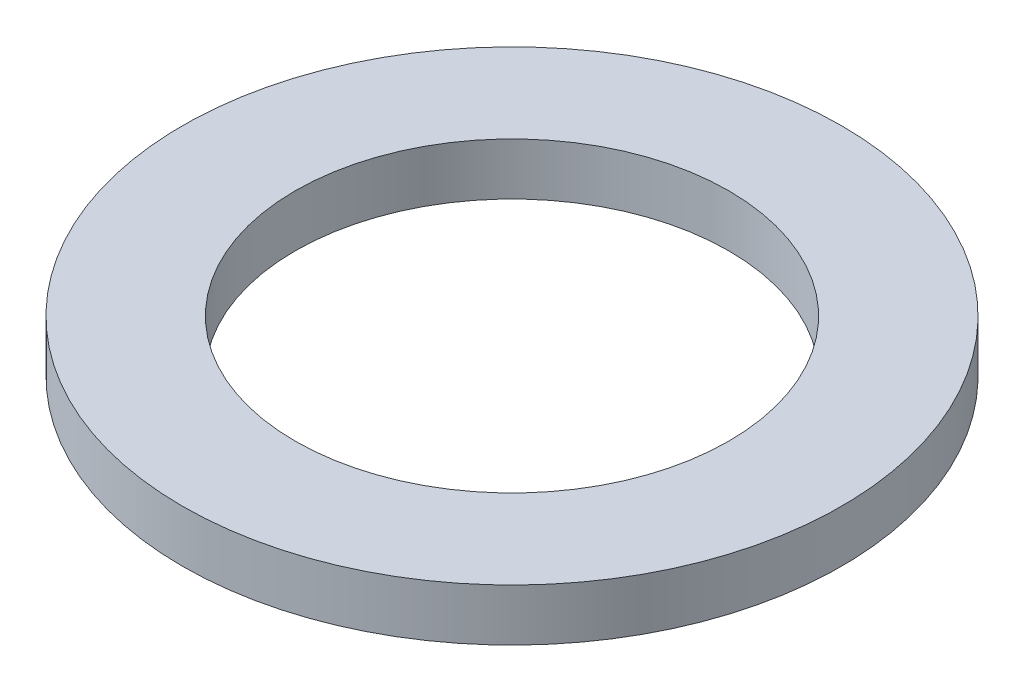
from build123d import *

# Parameters (mm, degrees)
SKETCH1_R           = 19
SKETCH1_R_2         = 12.5
BOSS_EXTRUDE1_DEPTH = 3


with BuildPart() as part:
    # Sketch1 → Boss-Extrude1 (new body)
    with BuildSketch(Plane(origin=(0, 0, 0), x_dir=(1, 0, 0), z_dir=(0, 1, 0))):
        Circle(SKETCH1_R)
        Circle(SKETCH1_R_2, mode=Mode.SUBTRACT)
    extrude(amount=BOSS_EXTRUDE1_DEPTH)


solid = part.part
